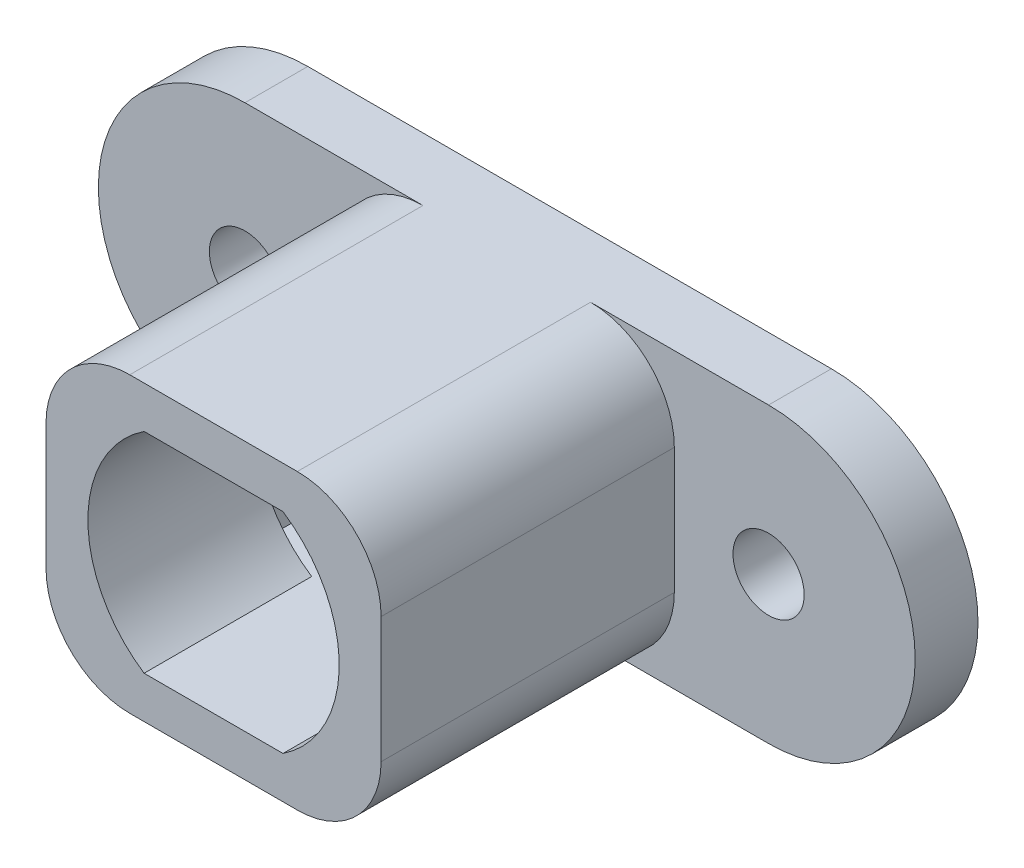
from build123d import *

# Parameters (mm, degrees)
SKETCH1_W                = 12
SKETCH1_H                = 10
BOSS_EXTRUDE3_DEPTH      = 3
SKETCH4_W                = 16
SKETCH4_H                = 14
SKETCH4_W_2              = 12
SKETCH4_H_2              = 10
BOSS_EXTRUDE4_DEPTH      = 6
SKETCH5_W                = 16
SKETCH5_H                = 14
BOSS_EXTRUDE5_DEPTH      = 8
M3_CLEARANCE_HOLE1_D     = 3.4
M3_CLEARANCE_HOLE1_DEPTH = 12
M3_CLEARANCE_HOLE1_TIP   = 1.021463052
FILLET1_R                = 4


with BuildPart() as part:
    # Sketch1 → Boss-Extrude3 (new body)
    with BuildSketch(Plane.XY):
        with BuildLine():
            Line((-12.5, 7), (12.5, 7))
            ThreePointArc((12.5, 7), (19.5, 0), (12.5, -7))
            Line((12.5, -7), (-12.5, -7))
            ThreePointArc((-12.5, -7), (-19.5, 0), (-12.5, 7))
        make_face()
        Rectangle(SKETCH1_W, SKETCH1_H, mode=Mode.SUBTRACT)
    extrude(amount=BOSS_EXTRUDE3_DEPTH)

    # Sketch4 → Boss-Extrude4 (add)
    with BuildSketch(Plane.XY.offset(3)):
        Rectangle(SKETCH4_W, SKETCH4_H)
        Rectangle(SKETCH4_W_2, SKETCH4_H_2, mode=Mode.SUBTRACT)
    extrude(amount=BOSS_EXTRUDE4_DEPTH)

    # Sketch5 → Boss-Extrude5 (add)
    with BuildSketch(Plane.XY.offset(9)):
        Rectangle(SKETCH5_W, SKETCH5_H)
        with BuildLine():
            Line((3.31662479, 5), (-3.31662479, 5))
            ThreePointArc((-3.31662479, 5), (-6, 0), (-3.31662479, -5))
            Line((-3.31662479, -5), (3.31662479, -5))
            ThreePointArc((3.31662479, -5), (6, 0), (3.31662479, 5))
        make_face(mode=Mode.SUBTRACT)
    extrude(amount=BOSS_EXTRUDE5_DEPTH)

    # M3 Clearance Hole1
    with Locations(Plane.XY.offset(3)):
        with Locations((-12.5, 0), (12.5, 0)):
            Hole(M3_CLEARANCE_HOLE1_D / 2, depth=M3_CLEARANCE_HOLE1_DEPTH)
            with Locations((0, 0, -(M3_CLEARANCE_HOLE1_DEPTH + M3_CLEARANCE_HOLE1_TIP / 2))):  # 118° drill point
                Cone(0, M3_CLEARANCE_HOLE1_D / 2, M3_CLEARANCE_HOLE1_TIP, mode=Mode.SUBTRACT)

    # Fillet1
    fillet1_edges = [part.edges().sort_by_distance(p)[0] for p in [
        (8, -7, 10),
        (8, 7, 10),
        (-8, 7, 10),
        (-8, -7, 10),
    ]]
    fillet(fillet1_edges, radius=FILLET1_R)


solid = part.part
